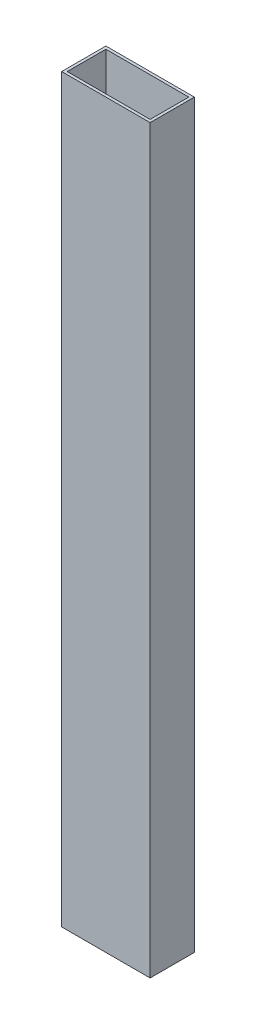
from build123d import *

# Parameters (mm, degrees)
SKETCH1_W           = 50.8
SKETCH1_H           = 25.4
SKETCH1_W_2         = 47.625
SKETCH1_H_2         = 22.225
BOSS_EXTRUDE1_DEPTH = 425.45


with BuildPart() as part:
    # Sketch1 → Boss-Extrude1 (new body)
    with BuildSketch(Plane(origin=(0, 0, 0), x_dir=(1, 0, 0), z_dir=(0, 1, 0))):
        with Locations((-23.8125, 11.1125)):
            Rectangle(SKETCH1_W, SKETCH1_H)
        with Locations((-23.8125, 11.1125)):
            Rectangle(SKETCH1_W_2, SKETCH1_H_2, mode=Mode.SUBTRACT)
    extrude(amount=BOSS_EXTRUDE1_DEPTH)


solid = part.part
